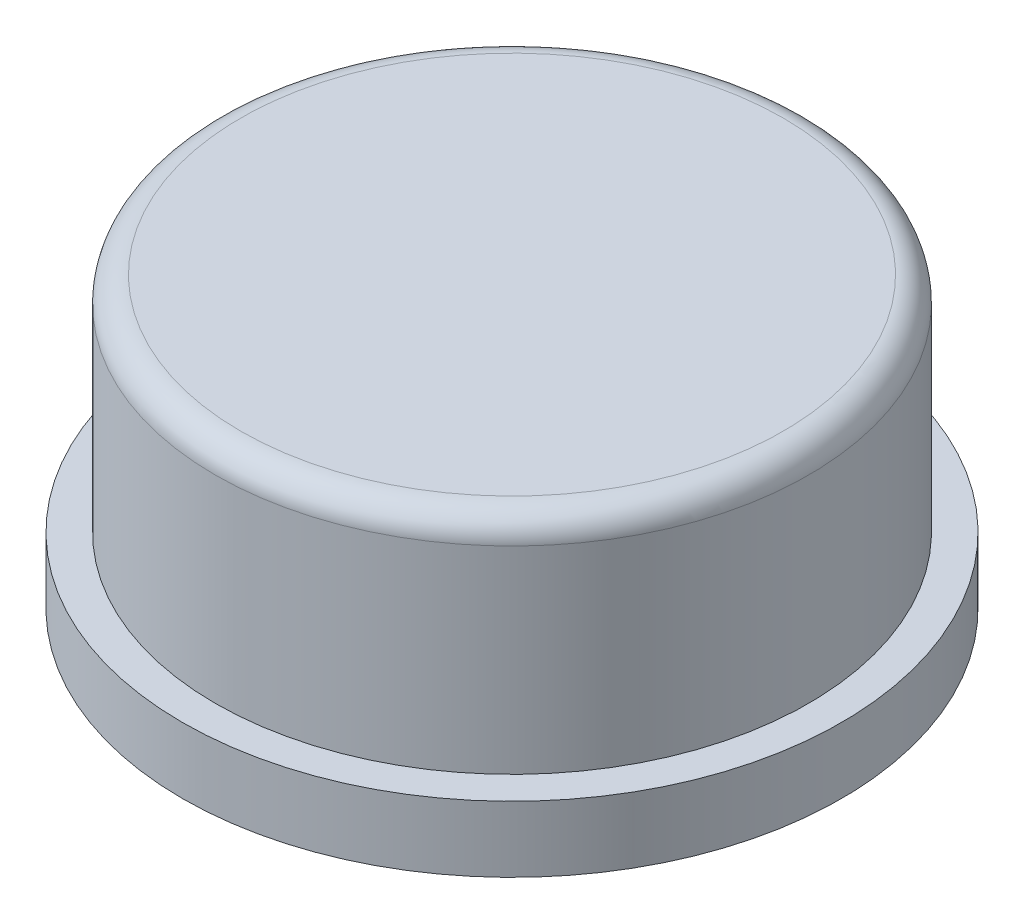
from build123d import *

# Parameters (mm, degrees)
SKETCH_5_R          = 6.5
EXTRUDE_5_DEPTH     = 1.3
SKETCH_6_R          = 5.85
EXTRUDE_6_DEPTH     = 4.4
FILLET_2_R          = 0.5
SKETCH_7_W          = 4
SKETCH_7_H          = 4
EXTRUDE_7_DEPTH     = 2
SKETCH_8_W          = 3.8
SKETCH_8_H          = 3.8
CUT_EXTRUDE_1_DEPTH = 2


with BuildPart() as part:
    # Эскиз5 → Бобышка-Вытянуть5 (new body)
    with BuildSketch(Plane(origin=(0, 0, 0), x_dir=(1, 0, 0), z_dir=(0, 1, 0))):
        Circle(SKETCH_5_R)
    extrude(amount=EXTRUDE_5_DEPTH)

    # Эскиз6 → Бобышка-Вытянуть6 (add)
    with BuildSketch(Plane(origin=(0, 1.3, 0), x_dir=(1, 0, 0), z_dir=(0, 1, 0))):
        Circle(SKETCH_6_R)
    extrude(amount=EXTRUDE_6_DEPTH)

    # Скругление2
    fillet_2_edges = [part.edges().sort_by_distance(p)[0] for p in [
        (-5.85, 5.7, 0),
    ]]
    fillet(fillet_2_edges, radius=FILLET_2_R)

    # Эскиз7 → Бобышка-Вытянуть7 (add)
    with BuildSketch(Plane.XZ):
        Rectangle(SKETCH_7_W, SKETCH_7_H)
    extrude(amount=EXTRUDE_7_DEPTH)

    # Эскиз8 → Вырез-Вытянуть1 (cut)
    with BuildSketch(Plane.XZ.offset(2)):
        Rectangle(SKETCH_8_W, SKETCH_8_H)
    extrude(amount=-CUT_EXTRUDE_1_DEPTH, mode=Mode.SUBTRACT)


solid = part.part
